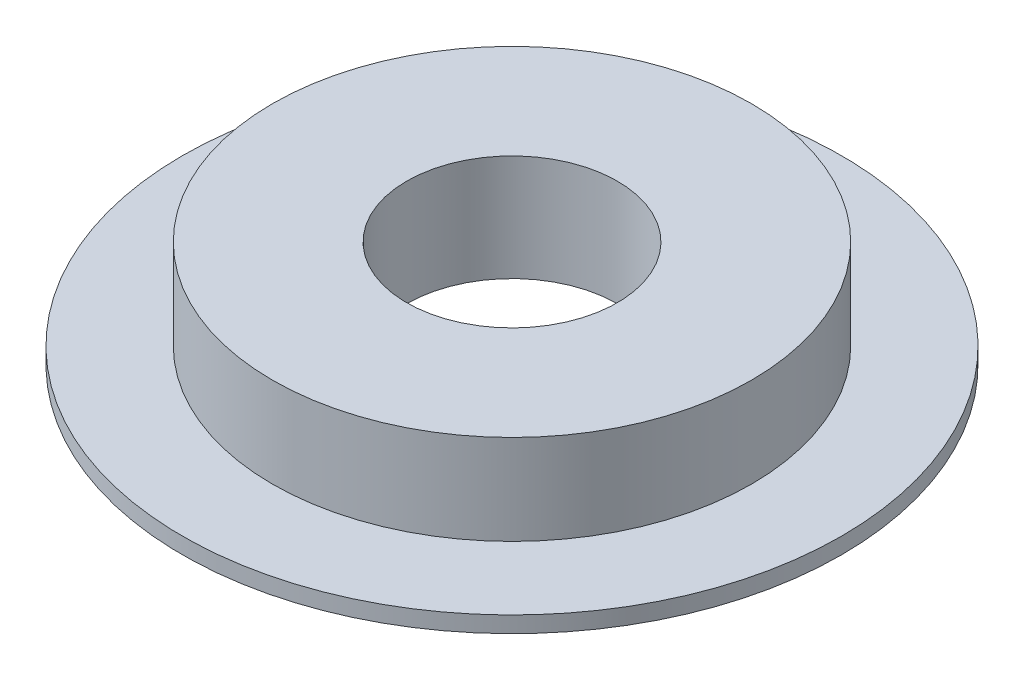
from build123d import *


with BuildPart() as part:
    # Croquis1 → Revolución1 (revolve)
    with BuildSketch(Plane.XY):
        Polygon((-41.12158728, 8.972889318), (-41.12158728, -2.827110682), (-66.02158728, -2.827110682), (-66.02158728, -1.027110682), (-56.02158728, -1.027110682), (-56.02158728, 8.972889318), align=None)
    revolve(axis=Axis((-29.42158728, 13.972889318, 0), (0, -1, 0)))


solid = part.part
